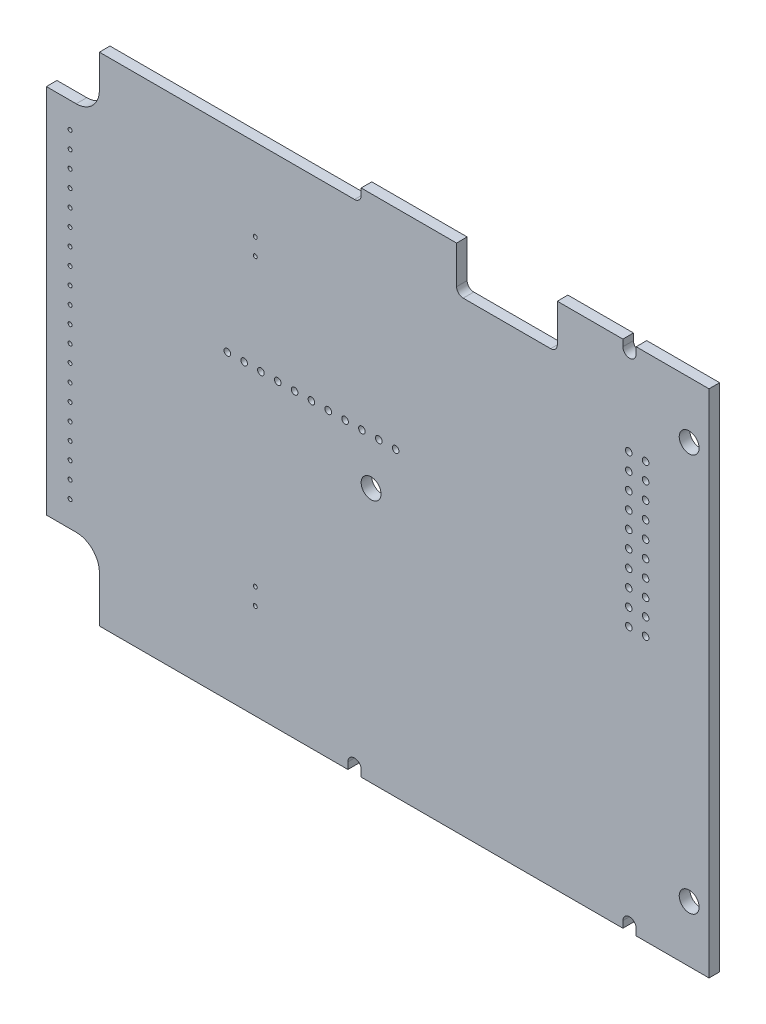
from build123d import *

# Parameters (mm, degrees)
BOSS_EXTRUDE1_DEPTH = 1.6
SKETCH3_R           = 1.5
CUT_EXTRUDE1_DEPTH  = 2.6
SKETCH4_W           = 50
SKETCH4_H           = 85
CUT_EXTRUDE2_DEPTH  = 2.6
SKETCH5_R           = 0.3
CUT_EXTRUDE3_DEPTH  = 2.6
SKETCH6_R           = 0.499999
CUT_EXTRUDE4_DEPTH  = 2.6
SKETCH7_R           = 0.499999
CUT_EXTRUDE5_DEPTH  = 2.6


with BuildPart() as part:
    # Board Outline → Boss-Extrude1 (new body)
    with BuildSketch(Plane.XY):
        with BuildLine():
            Line((394.450402667, 53.680474091), (394.450402667, -2.319525909))
            Line((394.450402667, -2.319525909), (375.450402667, -2.319525909))
            ThreePointArc((375.450402667, -2.319525909), (372.975528933, -3.344652175), (371.950402667, -5.819525909))
            Line((371.950402667, -5.819525909), (371.950402667, -12.819525909))
            Line((371.950402667, -12.819525909), (334.950402667, -12.819525909))
            Line((334.950402667, -12.819525909), (334.950402667, -11.819525909))
            ThreePointArc((334.950402667, -11.819525909), (333.950402667, -10.819525909), (332.950402667, -11.819525909))
            Line((332.950402667, -11.819525909), (332.950402667, -12.819525909))
            Line((332.950402667, -12.819525909), (293.450402667, -12.819525909))
            Line((293.450402667, -12.819525909), (293.450402667, -11.819525909))
            ThreePointArc((293.450402667, -11.819525909), (292.450402667, -10.819525909), (291.450402667, -11.819525909))
            Line((291.450402667, -11.819525909), (291.450402667, -12.819525909))
            Line((291.450402667, -12.819525909), (253.950402667, -12.819525909))
            Line((253.950402667, -12.819525909), (253.950402667, -5.819525909))
            ThreePointArc((253.950402667, -5.819525909), (252.925276401, -3.344652175), (250.450402667, -2.319525909))
            Line((250.450402667, -2.319525909), (245.950402667, -2.319525909))
            Line((245.950402667, -2.319525909), (245.950402667, 53.680474091))
            Line((245.950402667, 53.680474091), (250.450402667, 53.680474091))
            ThreePointArc((250.450402667, 53.680474091), (252.925276401, 54.705600357), (253.950402667, 57.180474091))
            Line((253.950402667, 57.180474091), (253.950402667, 62.180474091))
            Line((253.950402667, 62.180474091), (292.450402667, 62.180474091))
            ThreePointArc((292.450402667, 62.180474091), (293.157509449, 62.47336731), (293.450402667, 63.180474091))
            Line((293.450402667, 63.180474091), (293.450402667, 64.180474091))
            Line((293.450402667, 64.180474091), (307.850402667, 64.180474091))
            Line((307.850402667, 64.180474091), (307.850402667, 58.480474091))
            ThreePointArc((307.850402667, 58.480474091), (308.143295886, 57.77336731), (308.850402667, 57.480474091))
            Line((308.850402667, 57.480474091), (322.050402667, 57.480474091))
            ThreePointArc((322.050402667, 57.480474091), (322.757509449, 57.77336731), (323.050402667, 58.480474091))
            Line((323.050402667, 58.480474091), (323.050402667, 64.180474091))
            Line((323.050402667, 64.180474091), (332.950402667, 64.180474091))
            Line((332.950402667, 64.180474091), (332.950402667, 63.180474091))
            ThreePointArc((332.950402667, 63.180474091), (333.950402667, 62.180474091), (334.950402667, 63.180474091))
            Line((334.950402667, 63.180474091), (334.950402667, 64.180474091))
            Line((334.950402667, 64.180474091), (371.950402667, 64.180474091))
            Line((371.950402667, 64.180474091), (371.950402667, 57.180474091))
            ThreePointArc((371.950402667, 57.180474091), (372.975528933, 54.705600357), (375.450402667, 53.680474091))
            Line((375.450402667, 53.680474091), (394.450402667, 53.680474091))
        make_face()
    extrude(amount=BOSS_EXTRUDE1_DEPTH)

    # Sketch3 → Cut-Extrude1 (cut, through all)
    with BuildSketch(Plane.XY.offset(1.6)):
        with Locations((294.950402667, 25.680474091)):
            Circle(SKETCH3_R)
        with Locations((342.950402667, -4.319525909)):
            Circle(SKETCH3_R)
        with Locations((342.950402667, 55.680474091)):
            Circle(SKETCH3_R)
    extrude(amount=-CUT_EXTRUDE1_DEPTH, mode=Mode.SUBTRACT)

    # Sketch4 → Cut-Extrude2 (cut, through all)
    with BuildSketch(Plane.XY.offset(1.6)):
        with Locations((370.950402667, 25.680474091)):
            Rectangle(SKETCH4_W, SKETCH4_H)
    extrude(amount=-CUT_EXTRUDE2_DEPTH, mode=Mode.SUBTRACT)

    # Sketch5 → Cut-Extrude3 (cut, through all)
    with BuildSketch(Plane.XY.offset(1.6)):
        with Locations((249.525402667, 49.810474091)):
            Circle(SKETCH5_R)
        with Locations((277.475402667, 49.810474091)):
            Circle(SKETCH5_R)
        with Locations((277.475402667, 47.270474091)):
            Circle(SKETCH5_R)
        with Locations((277.475402667, 4.090474091)):
            Circle(SKETCH5_R)
        with Locations((249.525402667, 47.270474091)):
            Circle(SKETCH5_R)
        with Locations((249.525402667, 44.730474091)):
            Circle(SKETCH5_R)
        with Locations((249.525402667, 42.190474091)):
            Circle(SKETCH5_R)
        with Locations((249.525402667, 39.650474091)):
            Circle(SKETCH5_R)
        with Locations((249.525402667, 37.110474091)):
            Circle(SKETCH5_R)
        with Locations((249.525402667, 34.570474091)):
            Circle(SKETCH5_R)
        with Locations((249.525402667, 32.030474091)):
            Circle(SKETCH5_R)
        with Locations((249.525402667, 29.490474091)):
            Circle(SKETCH5_R)
        with Locations((249.525402667, 26.950474091)):
            Circle(SKETCH5_R)
        with Locations((249.525402667, 24.410474091)):
            Circle(SKETCH5_R)
        with Locations((249.525402667, 21.870474091)):
            Circle(SKETCH5_R)
        with Locations((249.525402667, 19.330474091)):
            Circle(SKETCH5_R)
        with Locations((249.525402667, 16.790474091)):
            Circle(SKETCH5_R)
        with Locations((249.525402667, 14.250474091)):
            Circle(SKETCH5_R)
        with Locations((249.525402667, 11.710474091)):
            Circle(SKETCH5_R)
        with Locations((249.525402667, 9.170474091)):
            Circle(SKETCH5_R)
        with Locations((249.525402667, 6.630474091)):
            Circle(SKETCH5_R)
        with Locations((249.525402667, 4.090474091)):
            Circle(SKETCH5_R)
        with Locations((249.525402667, 1.550474091)):
            Circle(SKETCH5_R)
        with Locations((277.475402667, 1.550474091)):
            Circle(SKETCH5_R)
    extrude(amount=-CUT_EXTRUDE3_DEPTH, mode=Mode.SUBTRACT)

    # Sketch6 → Cut-Extrude4 (cut, through all)
    with BuildSketch(Plane(origin=(0, 0, 0), x_dir=(-1, 0, 0), z_dir=(0, 0, -1))):
        with Locations((-333.834418667, 49.903457691)):
            Circle(SKETCH6_R)
        with Locations((-333.834418667, 47.363457691)):
            Circle(SKETCH6_R)
        with Locations((-336.374418667, 47.363457691)):
            Circle(SKETCH6_R)
        with Locations((-336.374418667, 44.823457691)):
            Circle(SKETCH6_R)
        with Locations((-333.834418667, 44.823457691)):
            Circle(SKETCH6_R)
        with Locations((-333.834418667, 34.663457691)):
            Circle(SKETCH6_R)
        with Locations((-333.834418667, 37.203457691)):
            Circle(SKETCH6_R)
        with Locations((-333.834418667, 39.743457691)):
            Circle(SKETCH6_R)
        with Locations((-333.834418667, 42.283457691)):
            Circle(SKETCH6_R)
        with Locations((-336.374418667, 42.283457691)):
            Circle(SKETCH6_R)
        with Locations((-336.374418667, 39.743457691)):
            Circle(SKETCH6_R)
        with Locations((-336.374418667, 37.203457691)):
            Circle(SKETCH6_R)
        with Locations((-333.834418667, 32.123457691)):
            Circle(SKETCH6_R)
        with Locations((-336.374418667, 34.663457691)):
            Circle(SKETCH6_R)
        with Locations((-336.374418667, 32.123457691)):
            Circle(SKETCH6_R)
        with Locations((-333.834418667, 29.583457691)):
            Circle(SKETCH6_R)
        with Locations((-336.374418667, 27.043457691)):
            Circle(SKETCH6_R)
        with Locations((-333.834418667, 27.043457691)):
            Circle(SKETCH6_R)
        with Locations((-336.374418667, 29.583457691)):
            Circle(SKETCH6_R)
        with Locations((-336.374418667, 49.903457691)):
            Circle(SKETCH6_R)
    extrude(amount=-CUT_EXTRUDE4_DEPTH, mode=Mode.SUBTRACT)

    # Sketch7 → Cut-Extrude5 (cut, through all)
    with BuildSketch(Plane.XY.offset(1.6)):
        with Locations((298.650402667, 32.616474091)):
            Circle(SKETCH7_R)
        with Locations((296.110402667, 32.616474091)):
            Circle(SKETCH7_R)
        with Locations((293.570402667, 32.616474091)):
            Circle(SKETCH7_R)
        with Locations((291.030402667, 32.616474091)):
            Circle(SKETCH7_R)
        with Locations((288.490402667, 32.616474091)):
            Circle(SKETCH7_R)
        with Locations((285.950402667, 32.616474091)):
            Circle(SKETCH7_R)
        with Locations((283.410402667, 32.616474091)):
            Circle(SKETCH7_R)
        with Locations((280.870402667, 32.616474091)):
            Circle(SKETCH7_R)
        with Locations((278.330402667, 32.616474091)):
            Circle(SKETCH7_R)
        with Locations((275.790402667, 32.616474091)):
            Circle(SKETCH7_R)
        with Locations((273.250402667, 32.616474091)):
            Circle(SKETCH7_R)
    extrude(amount=-CUT_EXTRUDE5_DEPTH, mode=Mode.SUBTRACT)


solid = part.part
